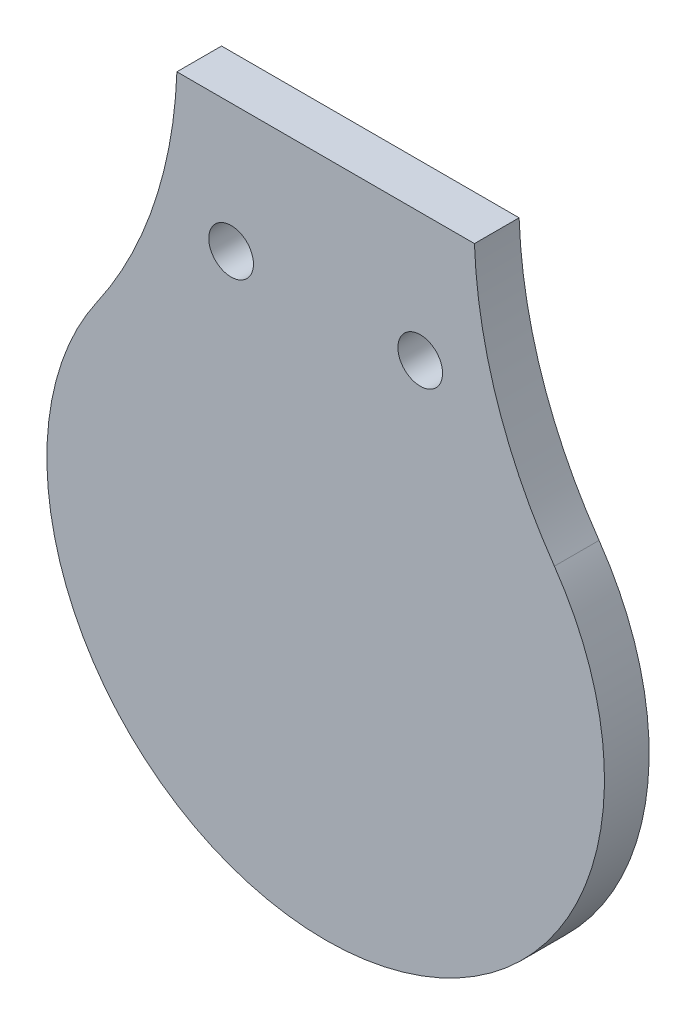
from build123d import *

# Parameters (mm, degrees)
SKETCH1_R           = 2.54
BOSS_EXTRUDE1_DEPTH = 5.08


with BuildPart() as part:
    # Sketch1 → Boss-Extrude1 (new body)
    with BuildSketch(Plane.XY):
        with BuildLine():
            Line((-16.923532905, -361.932719801), (16.923532905, -361.932719801))
            ThreePointArc((16.923532905, -361.932719801), (19.506243092, -376.204363349), (26.016534546, -389.164544931))
            ThreePointArc((26.016534546, -389.164544931), (0, -439.01304823), (-26.016534546, -389.164544931))
            ThreePointArc((-26.016534546, -389.164544931), (-19.506243092, -376.204363349), (-16.923532905, -361.932719801))
        make_face()
        with Locations((-10.756405179, -376.525575709)):
            Circle(SKETCH1_R, mode=Mode.SUBTRACT)
        with Locations((10.756405179, -376.525575709)):
            Circle(SKETCH1_R, mode=Mode.SUBTRACT)
    extrude(amount=BOSS_EXTRUDE1_DEPTH)


solid = part.part
